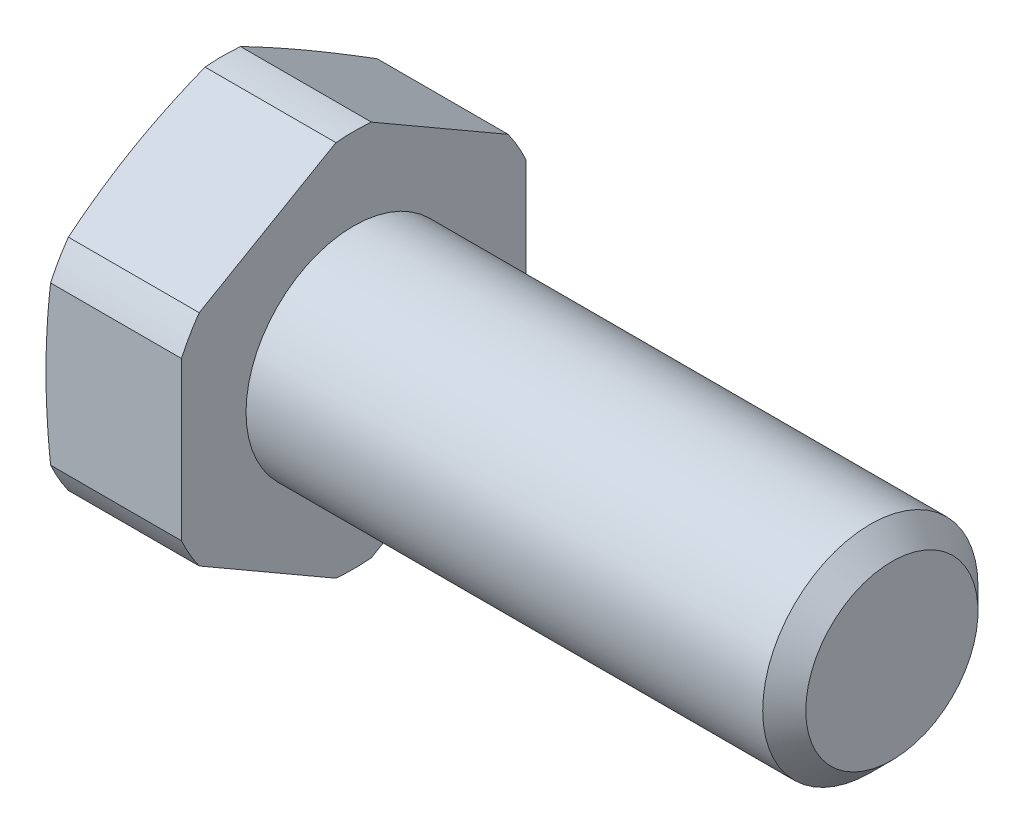
from build123d import *

# Parameters (mm, degrees)
SKETCH_2_OUTSIDE_W  = 27.614
SKETCH_2_OUTSIDE_H  = 27.614
CUT_EXTRUDE_1_DEPTH = 31.4


with BuildPart() as part:
    # Эскиз1 → Повернуть1 (revolve)
    with BuildSketch(Plane.XY):
        Polygon((-6.4, 0), (-6.4, 7.6), (-6.078460969, 8.8), (0, 8.8), (0, 5), (24, 5), (25, 4), (25, 0), align=None)
    revolve(axis=Axis((-1000, 0, 0), (1, 0, 0)))

    # Эскиз2 outside → Вырез-Вытянуть1 (cut)
    with BuildSketch(Plane.ZY.offset(6.4)):
        Rectangle(SKETCH_2_OUTSIDE_W, SKETCH_2_OUTSIDE_H)
        Polygon((0, 9.237604307), (-8, 4.618802154), (-8, -4.618802154), (0, -9.237604307), (8, -4.618802154), (8, 4.618802154), align=None, mode=Mode.SUBTRACT)
    extrude(amount=-CUT_EXTRUDE_1_DEPTH, mode=Mode.SUBTRACT)


solid = part.part
